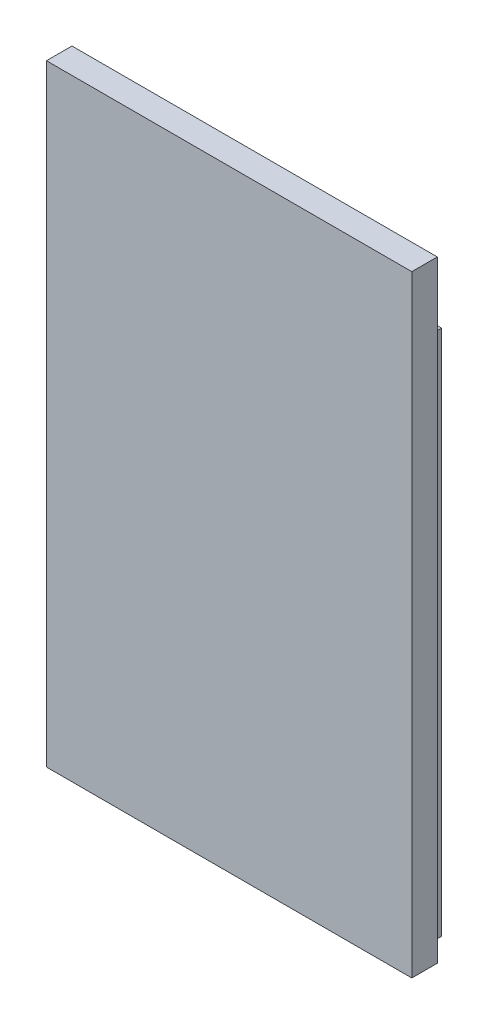
from build123d import *

# Parameters (mm, degrees)
SKETCH1_W           = 21.5
SKETCH1_H           = 36
BOSS_EXTRUDE1_DEPTH = 1.5
SKETCH2_W           = 14.5
SKETCH2_H           = 1
BOSS_EXTRUDE2_DEPTH = 3


with BuildPart() as part:
    # Sketch1 → Boss-Extrude1 (new body)
    with BuildSketch(Plane.XY):
        with Locations((10.75, 18)):
            Rectangle(SKETCH1_W, SKETCH1_H)
    extrude(amount=BOSS_EXTRUDE1_DEPTH)

    # Sketch2 → Boss-Extrude2 (add)
    with BuildSketch(Plane.XY.offset(1.5)):
        Polygon((3.75, 0), (4.75, 0), (4.75, 1), (4.75, 30), (3.75, 30), align=None)
        with Locations((12, 0.5)):
            Rectangle(SKETCH2_W, SKETCH2_H)
        Polygon((19.25, 0), (20.25, 0), (20.25, 31), (19.25, 31), (19.25, 30), (19.25, 1), align=None)
        Polygon((19.25, 30), (19.25, 31), (3.75, 31), (3.75, 30), (4.75, 30), align=None)
    extrude(amount=-BOSS_EXTRUDE2_DEPTH)


solid = part.part
